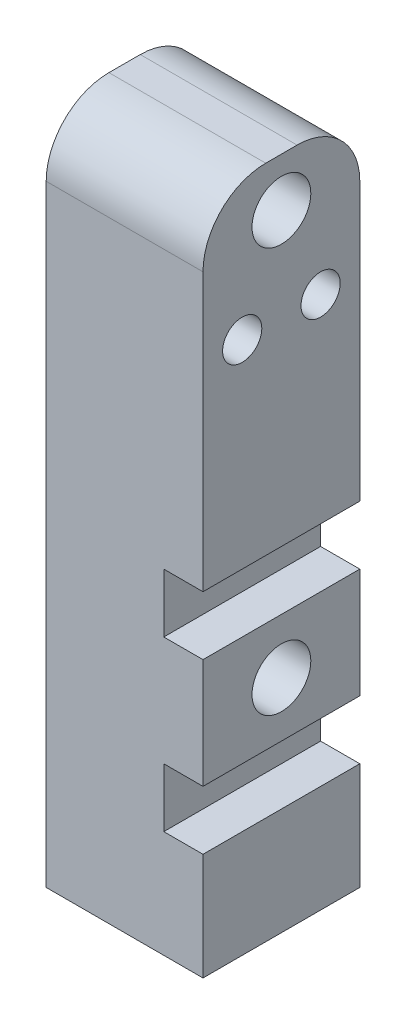
from build123d import *

# Parameters (mm, degrees)
BOSS_EXTRUDE1_DEPTH = 25.4
FILLET1_R           = 10.16
SKETCH2_R           = 4.7625
CUT_EXTRUDE1_DEPTH  = 25.4
SKETCH4_R           = 3.175
CUT_EXTRUDE3_DEPTH  = 25.4
SKETCH5_R           = 4.7625
CUT_EXTRUDE4_DEPTH  = 16.51
SKETCH6_R           = 3.175
CUT_EXTRUDE5_DEPTH  = 17.78


with BuildPart() as part:
    # Sketch1 → Boss-Extrude1 (new body)
    with BuildSketch(Plane.XY):
        Polygon((0, 0), (0, 109.22), (25.4, 109.22), (25.4, 54.185371462), (19.05, 54.185371462), (19.05, 44.660371462), (25.4, 44.660371462), (25.4, 26.880371462), (19.05, 26.880371462), (19.05, 17.355371462), (25.4, 17.355371462), (25.4, 0), align=None)
    extrude(amount=BOSS_EXTRUDE1_DEPTH)

    # Fillet1
    fillet1_edges = [part.edges().sort_by_distance(p)[0] for p in [
        (12.7, 109.22, 0),
        (12.7, 109.22, 25.4),
    ]]
    fillet(fillet1_edges, radius=FILLET1_R)

    # Sketch2 → Cut-Extrude1 (cut)
    with BuildSketch(Plane(origin=(25.4, 0, 0), x_dir=(0, 0, -1), z_dir=(1, 0, 0))):
        with Locations((-12.7, 35.770371462)):
            Circle(SKETCH2_R)
    extrude(amount=-CUT_EXTRUDE1_DEPTH, mode=Mode.SUBTRACT)

    # Sketch4 → Cut-Extrude3 (cut)
    with BuildSketch(Plane(origin=(25.4, 0, 0), x_dir=(0, 0, -1), z_dir=(1, 0, 0))):
        with Locations((-19.05, 86.36)):
            Circle(SKETCH4_R)
        with Locations((-6.35, 86.36)):
            Circle(SKETCH4_R)
    extrude(amount=-CUT_EXTRUDE3_DEPTH, mode=Mode.SUBTRACT)

    # Sketch5 → Cut-Extrude4 (cut)
    with BuildSketch(Plane(origin=(25.4, 0, 0), x_dir=(0, 0, -1), z_dir=(1, 0, 0))):
        with Locations((-12.7, 101.346)):
            Circle(SKETCH5_R)
    extrude(amount=-CUT_EXTRUDE4_DEPTH, mode=Mode.SUBTRACT)

    # Sketch6 → Cut-Extrude5 (cut)
    with BuildSketch(Plane.XZ):
        with Locations((12.7, 12.7)):
            Circle(SKETCH6_R)
    extrude(amount=-CUT_EXTRUDE5_DEPTH, mode=Mode.SUBTRACT)


solid = part.part
